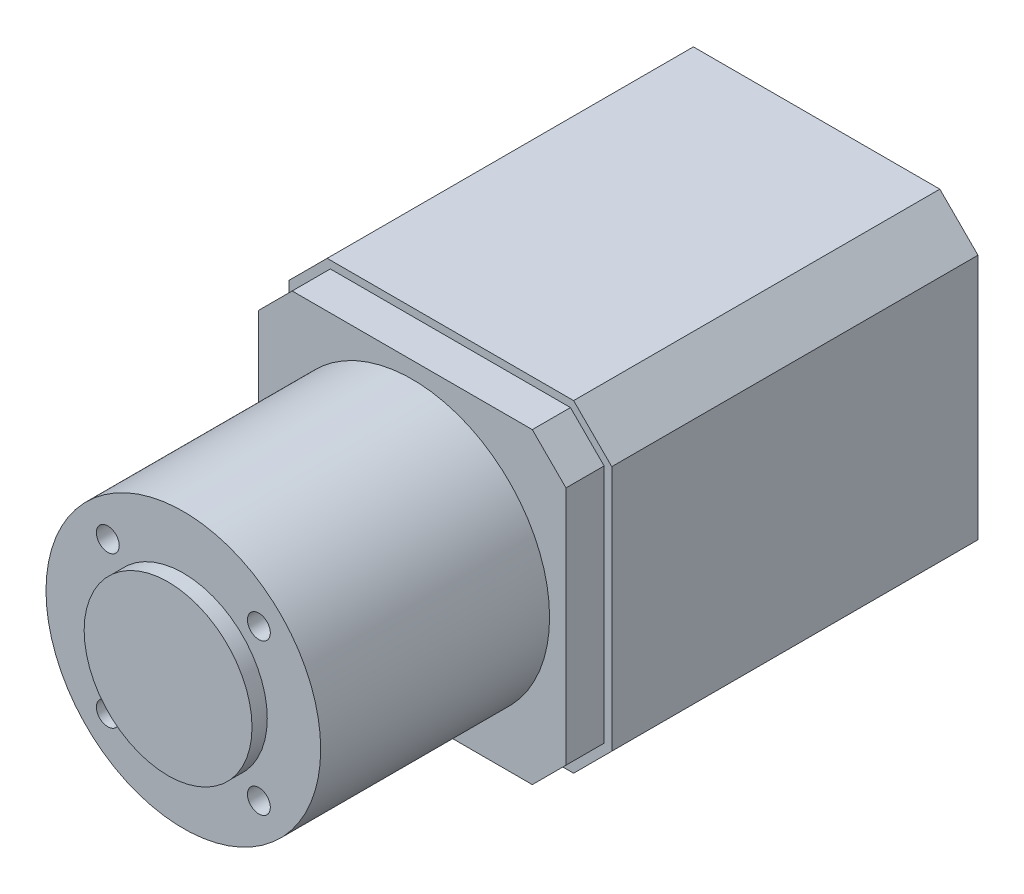
from build123d import *

# Parameters (mm, degrees)
SCHIZZO1_W                   = 42.3
SCHIZZO1_H                   = 42.3
ESTRUSIONE_ESTRUSIONE1_DEPTH = 48
SMUSSO1_SIZE                 = 5
ESTRUSIONE_ESTRUSIONE2_DEPTH = 5
SCHIZZO3_R                   = 18
ESTRUSIONE_ESTRUSIONE3_DEPTH = 30
SCHIZZO4_R                   = 11
ESTRUSIONE_ESTRUSIONE4_DEPTH = 2
SCHIZZO7_R                   = 1.5
TAGLIO_ESTRUSIONE2_DEPTH     = 30
RIPETIZIONECIRCOLARE1_COUNT  = 4


with BuildPart() as part:
    # Schizzo1 → Estrusione-Estrusione1 (new body)
    with BuildSketch(Plane.XY):
        Rectangle(SCHIZZO1_W, SCHIZZO1_H)
    extrude(amount=ESTRUSIONE_ESTRUSIONE1_DEPTH)

    # Smusso1
    smusso1_edges = [part.edges().sort_by_distance(p)[0] for p in [
        (-21.15, 21.15, 24),
        (21.15, 21.15, 24),
        (21.15, -21.15, 24),
        (-21.15, -21.15, 24),
    ]]
    chamfer(smusso1_edges, length=SMUSSO1_SIZE)

    # Schizzo2 → Estrusione-Estrusione2 (add)
    with BuildSketch(Plane.XY.offset(48)):
        Polygon((-20.15, 15.735786438), (-20.15, -15.735786438), (-15.735786438, -20.15), (15.735786438, -20.15), (20.15, -15.735786438), (20.15, 15.735786438), (15.735786438, 20.15), (-15.735786438, 20.15), align=None)
    extrude(amount=ESTRUSIONE_ESTRUSIONE2_DEPTH)

    # Schizzo3 → Estrusione-Estrusione3 (add)
    with BuildSketch(Plane.XY.offset(53)):
        Circle(SCHIZZO3_R)
    extrude(amount=ESTRUSIONE_ESTRUSIONE3_DEPTH)

    # Schizzo4 → Estrusione-Estrusione4 (add)
    with BuildSketch(Plane.XY.offset(83)):
        Circle(SCHIZZO4_R)
    extrude(amount=ESTRUSIONE_ESTRUSIONE4_DEPTH)

    # Schizzo7 → Taglio-Estrusione2 (cut)
    with BuildSketch(Plane.XY.offset(83)):
        with Locations((9.899494937, 9.899494937)):
            Circle(SCHIZZO7_R)
    taglio_estrusione2 = extrude(amount=-TAGLIO_ESTRUSIONE2_DEPTH, mode=Mode.SUBTRACT)

    # RipetizioneCircolare1: Taglio-Estrusione2 ×4 about axis
    ripetizionecircolare1_axis = Axis((0, 0, 0), (0, 0, 1))
    for i in range(1, RIPETIZIONECIRCOLARE1_COUNT):
        add(taglio_estrusione2.rotate(ripetizionecircolare1_axis, i * 360 / RIPETIZIONECIRCOLARE1_COUNT), mode=Mode.SUBTRACT)


solid = part.part
